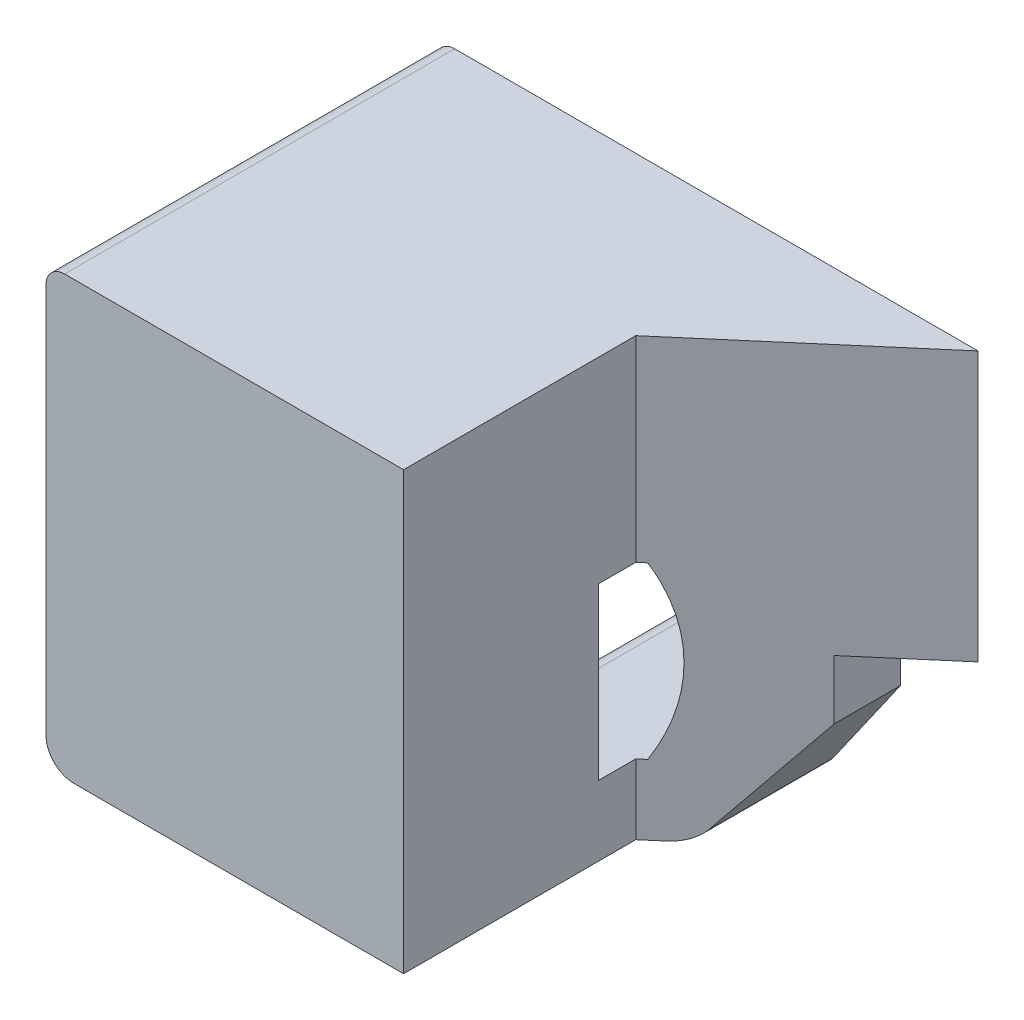
from build123d import *

# Parameters (mm, degrees)
EXTRUDE1_DEPTH          = 4.7752
EXTRUDE2_DEPTH          = 12.938
SKETCH33_W              = 2.286
SKETCH33_H              = 5.588
EXTRUDE30_DEPTH         = 10.668
EXTRUDE3_DEPTH          = 3.0988
EXTRUDE6_DEPTH          = 3.0988
EXTRUDE7_DEPTH          = 3.0988
SKETCH23_W              = 3.0988
SKETCH23_H              = 1.133450424
EXTRUDE20_DEPTH         = 2.54
EXTRUDE16_DEPTH         = 3.0988
FILLET1_R               = 0.762
EXTRUDE21_DEPTH         = 3.0988
FILLET2_R               = 0.762
EXTRUDE28_DEPTH         = 8.0612
EXTRUDE29_REACH         = 9.061
FILLET3_R               = 0.762
FILLET4_R               = 0.508
FILLET5_R               = 0.508
FILLET6_R               = 0.508
SKETCH35_R              = 1.016
EXTRUDE32_DEPTH         = 8.0612
BOSS_EXTRUDE1_DEPTH     = 5.334
BOSS_EXTRUDE2_DEPTH     = 5.334
SKETCH39_W              = 7.76878052
SKETCH39_H              = 12.502157979
CUT_EXTRUDE1_DEPTH      = 15.8590001
SKETCH40_W              = 5.041406472
SKETCH40_H              = 6.35
SKETCH40_W_2            = 0.038593528
SKETCH40_H_2            = 4.318
CUT_EXTRUDE2_DEPTH      = 1.0000001
CUT_EXTRUDE2_DEPTH_BACK = 12.9380001


with BuildPart() as part:
    # Sketch1 → Extrude1 (new body)
    with BuildSketch(Plane.XY):
        Polygon((-14.859, 11.938), (0, 11.938), (0, 4.572), (-3.175, 4.572), (-3.175, 0), (-14.859, 0), align=None)
    extrude(amount=-EXTRUDE1_DEPTH)

    # Sketch2 → Extrude2 (cut, through all)
    with BuildSketch(Plane(origin=(0, 11.938, 0), x_dir=(1, 0, 0), z_dir=(0, 1, 0))):
        Polygon((0, 0.5842), (-4.191, 4.7752), (0, 4.7752), align=None)
    extrude(amount=-EXTRUDE2_DEPTH, mode=Mode.SUBTRACT)

    # Sketch33 → Extrude30 (add)
    with BuildSketch(Plane.ZY.offset(14.859)):
        with Locations((-5.9182, 9.144)):
            Rectangle(SKETCH33_W, SKETCH33_H)
    extrude(amount=-EXTRUDE30_DEPTH)

    # Sketch5 → Extrude3 (cut)
    with BuildSketch(Plane.XY):
        with BuildLine():
            Line((-14.859, 8.121520088), (-14.859, 0))
            Line((-14.859, 0), (-8.374207602, 0))
            ThreePointArc((-8.374207602, 0), (-5.258197931, 4.182323512), (-8.261178378, 8.44652973))
            ThreePointArc((-8.261178378, 8.44652973), (-10.099280239, 8.911418564), (-11.9888, 9.0678))
            ThreePointArc((-11.9888, 9.0678), (-13.499883528, 8.825128765), (-14.859, 8.121520088))
        make_face()
    extrude(amount=-EXTRUDE3_DEPTH, mode=Mode.SUBTRACT)

    # Sketch8 → Extrude6 (add)
    with BuildSketch(Plane.XY):
        with BuildLine():
            Line((-5.916117419, 6.569687461), (-7.995771884, 6.569687461))
            ThreePointArc((-7.995771884, 6.569687461), (-8.381805974, 7.063274265), (-8.837117419, 7.493787609))
            Line((-8.837117419, 7.493787609), (-8.837117419, 8.601687461))
            ThreePointArc((-8.837117419, 8.601687461), (-7.16441835, 7.890723622), (-5.916117419, 6.569687461))
        make_face()
    extrude(amount=-EXTRUDE6_DEPTH)

    # Sketch9 → Extrude7 (add)
    with BuildSketch(Plane.XY):
        with BuildLine():
            Line((-5.916117419, 1.913912539), (-7.995771884, 1.913912539))
            ThreePointArc((-7.995771884, 1.913912539), (-8.381805974, 1.420325735), (-8.837117419, 0.989812391))
            Line((-8.837117419, 0.989812391), (-8.837117419, 0))
            Line((-8.837117419, 0), (-8.374207602, 0))
            ThreePointArc((-8.374207602, 0), (-6.971998867, 0.734557469), (-5.916117419, 1.913912539))
        make_face()
    extrude(amount=-EXTRUDE7_DEPTH)

    # Sketch23 → Extrude20 (add)
    with BuildSketch(Plane.ZY.offset(8.837117419)):
        with Locations((-1.5494, 8.060512821)):
            Rectangle(SKETCH23_W, SKETCH23_H)
    extrude(amount=-EXTRUDE20_DEPTH)

    # Sketch18 → Extrude16 (cut)
    with BuildSketch(Plane.XY):
        with BuildLine():
            Line((-4.903581733, 6.569687461), (-5.916117419, 6.569687461))
            ThreePointArc((-5.916117419, 6.569687461), (-5.2578, 4.2418), (-5.916117419, 1.913912539))
            Line((-5.916117419, 1.913912539), (-4.903581733, 1.913912539))
            ThreePointArc((-4.903581733, 1.913912539), (-4.3688, 4.2418), (-4.903581733, 6.569687461))
        make_face()
    extrude(amount=-EXTRUDE16_DEPTH, mode=Mode.SUBTRACT)

    # Fillet1
    fillet1_edges = [part.edges().sort_by_distance(p)[0] for p in [
        (0, 8.255, -0.5842),
    ]]
    fillet(fillet1_edges, radius=FILLET1_R)

    # Sketch24 → Extrude21 (add)
    with BuildSketch(Plane.XY):
        with BuildLine():
            Line((-8.837117419, 7.493787609), (-9.830149409, 8.301066631))
            ThreePointArc((-9.830149409, 8.301066631), (-10.843412246, 8.870424655), (-11.9888, 9.0678))
            Line((-11.9888, 9.0678), (-8.837117419, 9.0678))
            Line((-8.837117419, 9.0678), (-8.837117419, 7.493787609))
        make_face()
    extrude(amount=-EXTRUDE21_DEPTH)

    # Fillet2
    fillet2_edges = [part.edges().sort_by_distance(p)[0] for p in [
        (-14.859, 0, -3.937),
    ]]
    fillet(fillet2_edges, radius=FILLET2_R)

    # Sketch31 → Extrude28 (cut, through all)
    with BuildSketch(Plane.XY):
        Polygon((-3.175, 1.499352844), (-4.224858164, 0), (-3.175, 0), align=None)
    extrude(amount=-EXTRUDE28_DEPTH, mode=Mode.SUBTRACT)

    # Extrude29: up to this face of the body (flat: up to its plane)
    extrude29_end = Plane(part.part.faces().sort_by_distance((-2.383005057, 7.601249614, -2.967205057))[0])
    # Sketch32 → Extrude29 (add, up to the picked face)
    with BuildSketch(Plane.XY, mode=Mode.PRIVATE) as extrude29_sk1:
        Polygon((-3.175, 1.499352844), (-2.159, 2.950351219), (-2.159, 4.572), (-3.175, 4.572), align=None)
    extrude29_tool1 = split(extrude(extrude29_sk1.sketch, amount=-EXTRUDE29_REACH, mode=Mode.PRIVATE), bisect_by=extrude29_end, keep=Keep.BOTH, mode=Mode.PRIVATE)
    add(extrude29_tool1.solids().sort_by_distance((-2.719341, 3.361051, 0))[0])

    # Fillet3
    fillet3_edges = [part.edges().sort_by_distance(p)[0] for p in [
        (-4.224858164, 0, -2.3876),
    ]]
    fillet(fillet3_edges, radius=FILLET3_R)

    # Fillet4
    fillet4_edges = [part.edges().sort_by_distance(p)[0] for p in [
        (-3.078168199, 1.637642987, 0),
        (-4.269677813, 0.086097745, 0),
        (-6.729323838, 0, 0),
    ]]
    fillet(fillet4_edges, radius=FILLET4_R)

    # Fillet5
    fillet5_edges = [part.edges().sort_by_distance(p)[0] for p in [
        (-9.525, 11.938, -7.0612),
        (-9.525, 6.35, -7.0612),
        (-7.4295, 11.938, 0),
        (-14.859, 11.938, -3.5306),
    ]]
    fillet(fillet5_edges, radius=FILLET5_R)

    # Fillet6
    fillet6_edges = [part.edges().sort_by_distance(p)[0] for p in [
        (-7.995771884, 6.569687461, -1.5494),
        (-8.837117419, 0.989812391, -1.5494),
        (-7.995771884, 1.913912539, -1.5494),
    ]]
    fillet(fillet6_edges, radius=FILLET6_R)

    # Sketch35 → Extrude32 (cut, through all)
    with BuildSketch(Plane.XY):
        with Locations((-6.731, 8.763)):
            Circle(SKETCH35_R)
    extrude(amount=-EXTRUDE32_DEPTH, mode=Mode.SUBTRACT)

    # Sketch37 → Boss-Extrude1 (add)
    with BuildSketch(Plane.XY):
        with BuildLine():
            Line((-8.837117419, 0.508), (-8.837117419, 0))
            Line((-8.837117419, 0), (-4.621530256, 0))
            ThreePointArc((-4.621530256, 0), (-4.269677813, 0.086097745), (-3.997336399, 0.324934756))
            Line((-3.997336399, 0.324934756), (-2.159, 2.950351219))
            Line((-2.159, 2.950351219), (-2.159, 3.836022191))
            Line((-2.159, 3.836022191), (-2.159, 4.572))
            Line((-2.159, 4.572), (0, 4.572))
            Line((0, 4.572), (0, 11.43))
            Line((0, 11.43), (0, 11.878036743))
            add(Edge.make_bspline(
                [(0, 11.878036743), (0, 11.918150491), (-0.011858122, 11.938), (-0.038593528, 11.938)],
                knots=[0, 0, 0, 0, 1, 1, 1, 1], degree=3))
            Line((-0.038593528, 11.938), (-14.351, 11.938))
            ThreePointArc((-14.351, 11.938), (-14.710210245, 11.789210245), (-14.859, 11.43))
            Line((-14.859, 11.43), (-14.859, 8.121520088))
            ThreePointArc((-14.859, 8.121520088), (-13.499883528, 8.825128765), (-11.9888, 9.0678))
            ThreePointArc((-11.9888, 9.0678), (-10.843412246, 8.870424655), (-9.830149409, 8.301066631))
            Line((-9.830149409, 8.301066631), (-8.837117419, 7.493787609))
            ThreePointArc((-8.837117419, 7.493787609), (-8.466362979, 7.153440508), (-8.139079327, 6.771105032))
            ThreePointArc((-8.139079327, 6.771105032), (-7.96020818, 6.622820517), (-7.734022276, 6.569687461))
            Line((-7.734022276, 6.569687461), (-4.903581733, 6.569687461))
            ThreePointArc((-4.903581733, 6.569687461), (-4.3688, 4.2418), (-4.903581733, 1.913912539))
            Line((-4.903581733, 1.913912539), (-7.734022276, 1.913912539))
            ThreePointArc((-7.734022276, 1.913912539), (-7.96020818, 1.860779483), (-8.139079327, 1.712494968))
            ThreePointArc((-8.139079327, 1.712494968), (-8.390857142, 1.410416216), (-8.66983986, 1.133265926))
            ThreePointArc((-8.66983986, 1.133265926), (-8.793418506, 0.962601304), (-8.837117419, 0.756473917))
            Line((-8.837117419, 0.756473917), (-8.837117419, 0.508))
        make_face()
    extrude(amount=BOSS_EXTRUDE1_DEPTH)

    # Sketch38 → Boss-Extrude2 (add)
    with BuildSketch(Plane.XY.offset(5.334)):
        with BuildLine():
            Line((-0.038593528, 11.938), (-14.351, 11.938))
            ThreePointArc((-14.351, 11.938), (-14.710210245, 11.789210245), (-14.859, 11.43))
            Line((-14.859, 11.43), (-14.859, 0.762))
            ThreePointArc((-14.859, 0.762), (-14.635815367, 0.223184633), (-14.097, 0))
            Line((-14.097, 0), (-4.621530256, 0))
            ThreePointArc((-4.621530256, 0), (-4.269677813, 0.086097745), (-3.997336399, 0.324934756))
            Line((-3.997336399, 0.324934756), (-2.159, 2.950351219))
            Line((-2.159, 2.950351219), (-2.159, 4.572))
            Line((-2.159, 4.572), (0, 4.572))
            Line((0, 4.572), (0, 11.878036743))
            add(Edge.make_bspline(
                [(0, 11.878036743), (0, 11.918150491), (-0.011858122, 11.938), (-0.038593528, 11.938)],
                knots=[0, 0, 0, 0, 1, 1, 1, 1], degree=3))
        make_face()
    extrude(amount=BOSS_EXTRUDE2_DEPTH)

    # Sketch39 → Cut-Extrude1 (cut, through all)
    with BuildSketch(Plane.ZY.offset(14.859)):
        with Locations((-3.88439026, 6.25107899)):
            Rectangle(SKETCH39_W, SKETCH39_H)
    extrude(amount=-CUT_EXTRUDE1_DEPTH, mode=Mode.SUBTRACT)

    # Sketch40 → Cut-Extrude2 (cut, two sides)
    with BuildSketch(Plane(origin=(0, 11.938, 0), x_dir=(1, 0, 0), z_dir=(0, 1, 0))) as cut_extrude2_sk:
        Polygon((-0.038593528, 0), (-5.08, -4.318), (-0.038593528, -4.318), align=None)
        with Locations((-2.559296764, -7.493)):
            Rectangle(SKETCH40_W, SKETCH40_H)
        with Locations((-0.019296764, -2.159)):
            Rectangle(SKETCH40_W_2, SKETCH40_H_2)
        with Locations((-0.019296764, -7.493)):
            Rectangle(SKETCH40_W_2, SKETCH40_H)
    extrude(amount=CUT_EXTRUDE2_DEPTH, mode=Mode.SUBTRACT)
    extrude(cut_extrude2_sk.sketch, amount=-CUT_EXTRUDE2_DEPTH_BACK, mode=Mode.SUBTRACT)


solid = part.part
